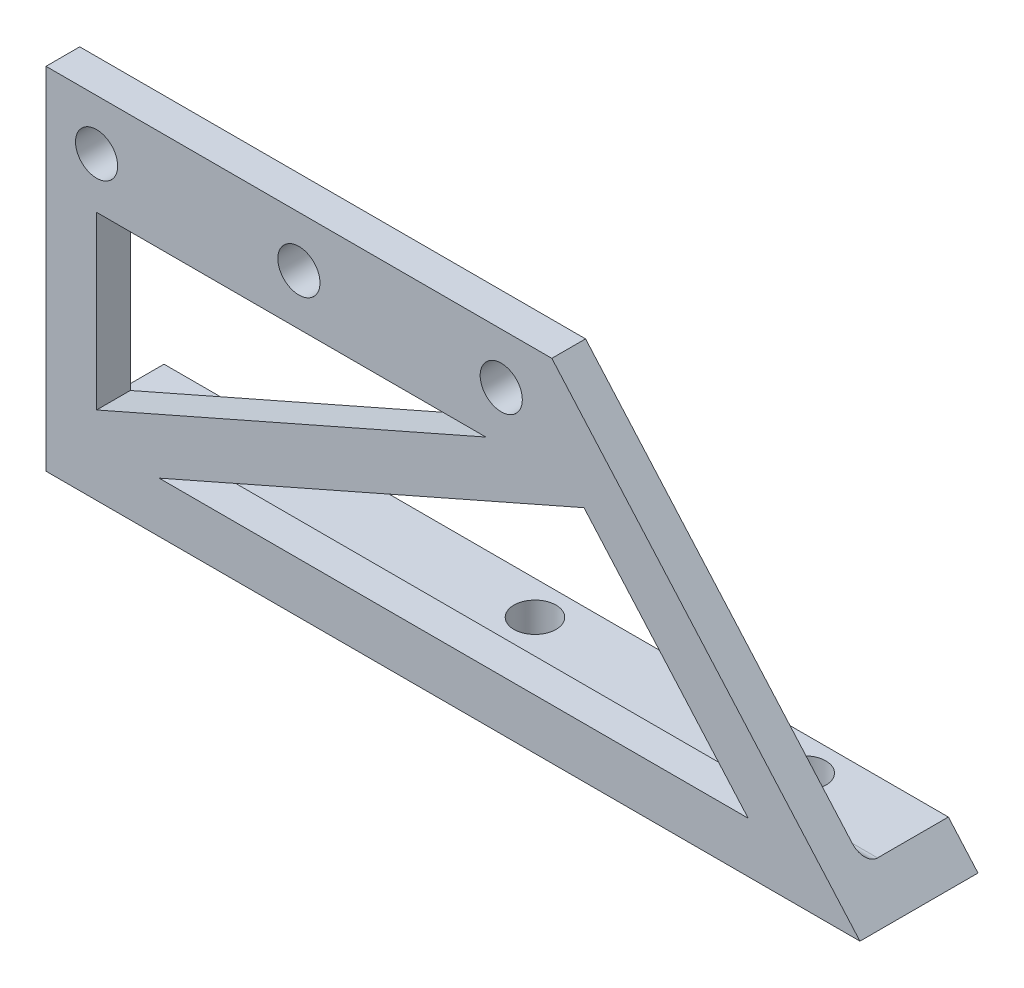
from build123d import *

# Parameters (mm, degrees)
SKETCH1_R           = 3.96875
BOSS_EXTRUDE1_DEPTH = 6.35
SKETCH2_W           = 153.277121284
SKETCH2_H           = 15.875
SKETCH2_R           = 3.96875
BOSS_EXTRUDE2_DEPTH = 6.35
FILLET1_R           = 2.54
CUT_EXTRUDE1_DEPTH  = 16.875


with BuildPart() as part:
    # Sketch1 → Boss-Extrude1 (new body)
    with BuildSketch(Plane.XY):
        Polygon((0, 0), (0, 66.04), (95.25, 66.04), (153.277121284, 0), align=None)
        with Locations((9.525, 56.515)):
            Circle(SKETCH1_R, mode=Mode.SUBTRACT)
        with Locations((47.625, 56.515)):
            Circle(SKETCH1_R, mode=Mode.SUBTRACT)
        with Locations((85.725, 56.515)):
            Circle(SKETCH1_R, mode=Mode.SUBTRACT)
        Polygon((9.525, 14.756535386), (9.525, 46.99), (82.829969346, 46.99), align=None, mode=Mode.SUBTRACT)
        Polygon((21.290817509, 9.525), (101.311219354, 44.71135659), (132.228284487, 9.525), align=None, mode=Mode.SUBTRACT)
    extrude(amount=BOSS_EXTRUDE1_DEPTH)

    # Sketch2 → Boss-Extrude2 (add)
    with BuildSketch(Plane.XZ):
        with Locations((76.638560642, -7.9375)):
            Rectangle(SKETCH2_W, SKETCH2_H)
        with Locations((25.4, -9.525)):
            Circle(SKETCH2_R, mode=Mode.SUBTRACT)
        with Locations((76.2, -9.525)):
            Circle(SKETCH2_R, mode=Mode.SUBTRACT)
        with Locations((127, -9.525)):
            Circle(SKETCH2_R, mode=Mode.SUBTRACT)
    extrude(amount=-BOSS_EXTRUDE2_DEPTH)

    # Fillet1
    fillet1_edges = [part.edges().sort_by_distance(p)[0] for p in [
        (73.848795196, 6.35, 0),
    ]]
    fillet(fillet1_edges, radius=FILLET1_R)

    # Sketch3 → Cut-Extrude1 (cut, through all)
    with BuildSketch(Plane(origin=(0, 0, 0), x_dir=(-1, 0, 0), z_dir=(0, 0, -1))):
        Polygon((-153.277121284, 0), (-143.888240191, 10.685377693), (-163.562021825, 13.552350256), (-165.283233358, 4.245452075), align=None)
    extrude(amount=CUT_EXTRUDE1_DEPTH, mode=Mode.SUBTRACT)


solid = part.part
